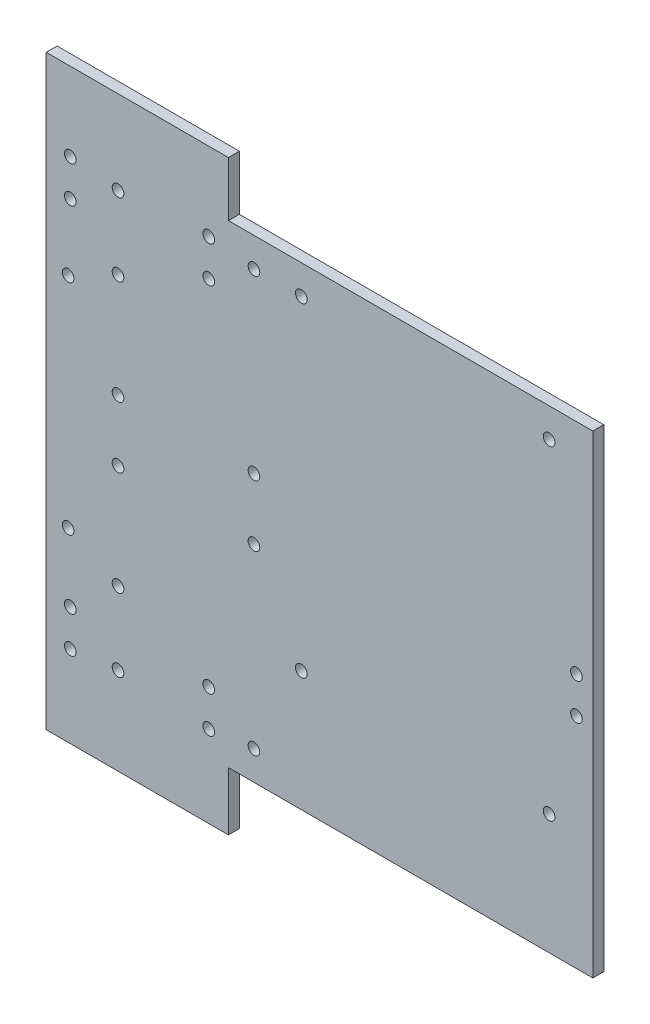
from build123d import *

# Parameters (mm, degrees)
SKETCH1_W           = 150
SKETCH1_H           = 130
BOSS_EXTRUDE1_DEPTH = 3
SKETCH2_R           = 1.6
CUT_EXTRUDE1_DEPTH  = 23
SKETCH3_W           = 50
SKETCH3_H           = 15
SKETCH3_H_2         = 16
BOSS_EXTRUDE2_DEPTH = 3


with BuildPart() as part:
    # Sketch1 → Boss-Extrude1 (new body)
    with BuildSketch(Plane.XY):
        Rectangle(SKETCH1_W, SKETCH1_H)
    extrude(amount=BOSS_EXTRUDE1_DEPTH)

    # Sketch2 → Cut-Extrude1 (cut)
    with BuildSketch(Plane.XY.offset(3)):
        with Locations((63, 57)):
            Circle(SKETCH2_R)
        with Locations((70.5, 5)):
            Circle(SKETCH2_R)
        with Locations((-5, 57)):
            Circle(SKETCH2_R)
        with Locations((-5, -32)):
            Circle(SKETCH2_R)
        with Locations((63, -32)):
            Circle(SKETCH2_R)
        with Locations((70.5, -5)):
            Circle(SKETCH2_R)
        with Locations((-18, 57)):
            Circle(SKETCH2_R)
        with Locations((-18, 8.4)):
            Circle(SKETCH2_R)
        with Locations((-55.3, 8.4)):
            Circle(SKETCH2_R)
        with Locations((-55.3, 57)):
            Circle(SKETCH2_R)
        with Locations((-18, -57)):
            Circle(SKETCH2_R)
        with Locations((-55.3, -57)):
            Circle(SKETCH2_R)
        with Locations((-55.3, -8.4)):
            Circle(SKETCH2_R)
        with Locations((-18, -8.4)):
            Circle(SKETCH2_R)
        with Locations((-30.4, 58.5)):
            Circle(SKETCH2_R)
        with Locations((-68.4, 58.5)):
            Circle(SKETCH2_R)
        with Locations((-68.4, 48.5)):
            Circle(SKETCH2_R)
        with Locations((-30.4, 48.5)):
            Circle(SKETCH2_R)
        with Locations((-68.4, -48.5)):
            Circle(SKETCH2_R)
        with Locations((-68.4, -58.5)):
            Circle(SKETCH2_R)
        with Locations((-30.4, -58.5)):
            Circle(SKETCH2_R)
        with Locations((-30.4, -48.5)):
            Circle(SKETCH2_R)
        with Locations((-69, -30)):
            Circle(SKETCH2_R)
        with Locations((-69, 30)):
            Circle(SKETCH2_R)
        with Locations((-55.3, 37)):
            Circle(SKETCH2_R)
        with Locations((-55.3, -37)):
            Circle(SKETCH2_R)
    extrude(amount=-CUT_EXTRUDE1_DEPTH, mode=Mode.SUBTRACT)

    # Sketch3 → Boss-Extrude2 (add)
    with BuildSketch(Plane(origin=(0, 0, 0), x_dir=(-1, 0, 0), z_dir=(0, 0, -1))):
        with Locations((50, 72.5)):
            Rectangle(SKETCH3_W, SKETCH3_H)
        with Locations((50, -73)):
            Rectangle(SKETCH3_W, SKETCH3_H_2)
    extrude(amount=-BOSS_EXTRUDE2_DEPTH)


solid = part.part
